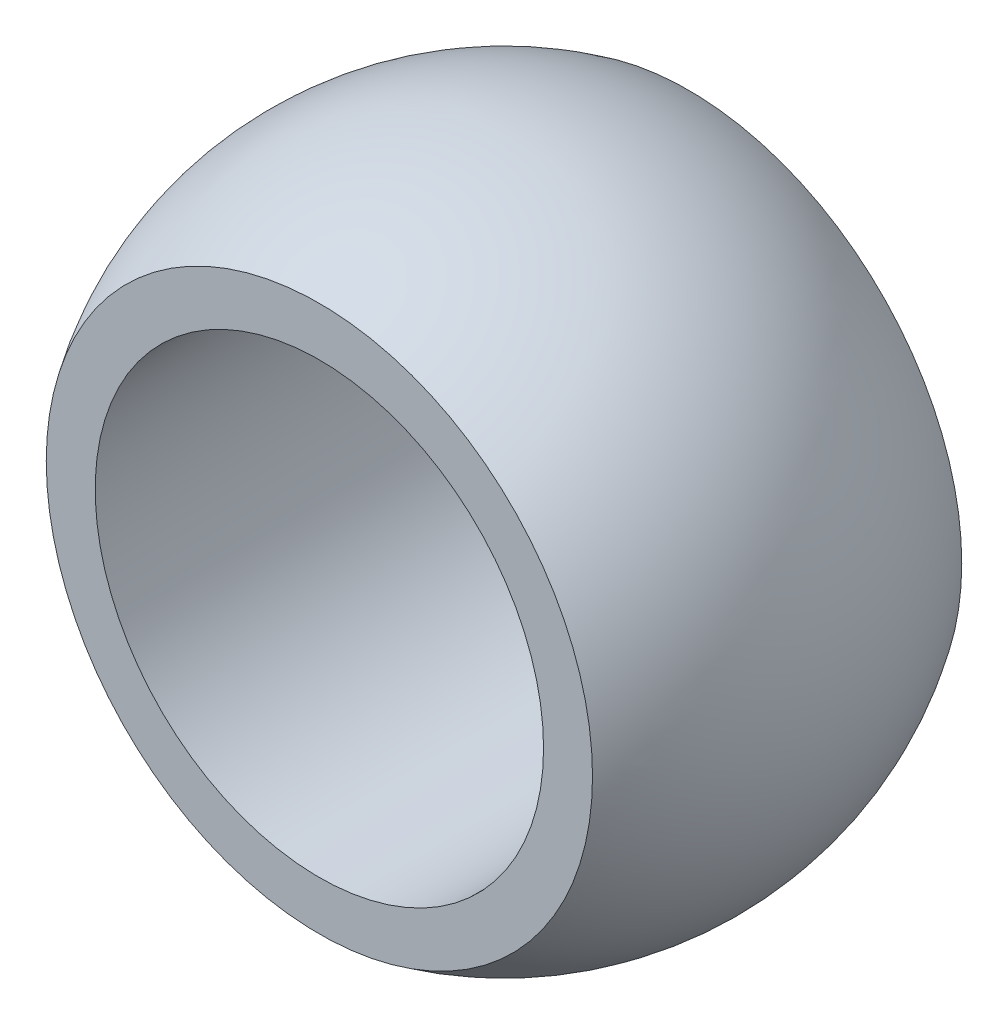
from build123d import *

# Parameters (mm, degrees)
ESQUISSE_FACES_W = 25
ESQUISSE_FACES_H = 7
FACES_2_DEPTH    = 28
DIA_AL_SAGE_R    = 8.5
AL_SAGE_DEPTH    = 20.5


with BuildPart() as part:
    # Esquisse sphère → Sphère extérieur (revolve)
    with BuildSketch(Plane.XY):
        with BuildLine():
            Line((0, 12.5), (0, -12.5))
            ThreePointArc((0, -12.5), (12.5, 0), (0, 12.5))
        make_face()
    revolve(axis=Axis((0, 17, 0), (0, -1, 0)))

    # Esquisse faces → Faces 2 (cut, symmetric)
    with BuildSketch(Plane(origin=(0, 0, 0), x_dir=(1, 0, 0), z_dir=(0, 1, 0))):
        with Locations((1.5, -10.5)):
            Rectangle(ESQUISSE_FACES_W, ESQUISSE_FACES_H)
        with Locations((1.5, 10.5)):
            Rectangle(ESQUISSE_FACES_W, ESQUISSE_FACES_H)
    extrude(amount=FACES_2_DEPTH, both=True, mode=Mode.SUBTRACT)

    # Dia alésage → Alésage (cut, through all)
    with BuildSketch(Plane.XY.offset(7)):
        Circle(DIA_AL_SAGE_R)
    extrude(amount=-AL_SAGE_DEPTH, mode=Mode.SUBTRACT)


solid = part.part
